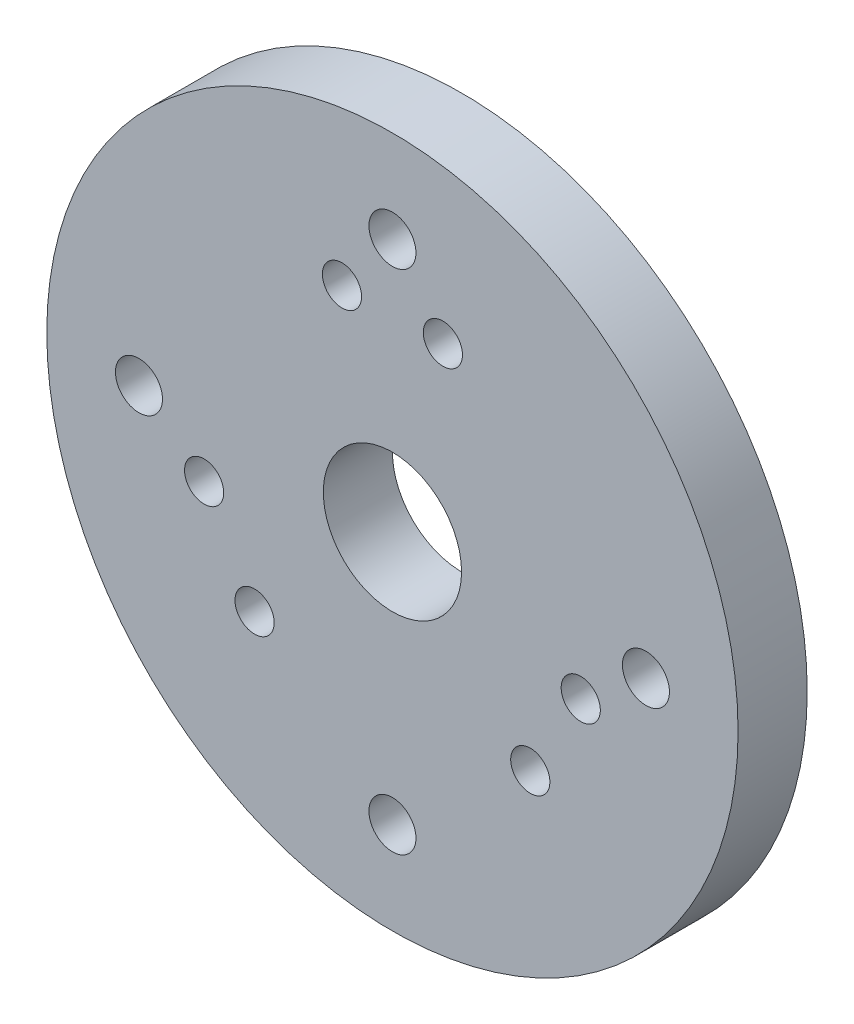
from build123d import *

# Parameters (mm, degrees)
ESQUISSE1_R        = 75
ESQUISSE1_R_2      = 15
ESQUISSE1_R_3      = 5.1
ESQUISSE1_R_4      = 4.25
BOSS_EXTRU_1_DEPTH = 7.5


with BuildPart() as part:
    # Esquisse1 → Boss.-Extru.1 (new body, symmetric)
    with BuildSketch(Plane.XY):
        Circle(ESQUISSE1_R)
        Circle(ESQUISSE1_R_2, mode=Mode.SUBTRACT)
        with Locations((0, 55)):
            Circle(ESQUISSE1_R_3, mode=Mode.SUBTRACT)
        with Locations((-55, 0)):
            Circle(ESQUISSE1_R_3, mode=Mode.SUBTRACT)
        with Locations((0, -55)):
            Circle(ESQUISSE1_R_3, mode=Mode.SUBTRACT)
        with Locations((55, 0)):
            Circle(ESQUISSE1_R_3, mode=Mode.SUBTRACT)
        with Locations((10.948045608, 40.858662452)):
            Circle(ESQUISSE1_R_4, mode=Mode.SUBTRACT)
        with Locations(Location((-10.948045608, 40.858662452, 0), (0, 0, 180))):  # turned: the seam where the file's is
            Circle(ESQUISSE1_R_4, mode=Mode.SUBTRACT)
        with Locations((29.910616844, -29.910616844)):
            Circle(ESQUISSE1_R_4, mode=Mode.SUBTRACT)
        with Locations(Location((40.858662452, -10.948045608, 0), (0, 0, 180))):  # turned: the seam where the file's is
            Circle(ESQUISSE1_R_4, mode=Mode.SUBTRACT)
        with Locations((-40.858662452, -10.948045608)):
            Circle(ESQUISSE1_R_4, mode=Mode.SUBTRACT)
        with Locations(Location((-29.910616844, -29.910616844, 0), (0, 0, 180))):  # turned: the seam where the file's is
            Circle(ESQUISSE1_R_4, mode=Mode.SUBTRACT)
    extrude(amount=BOSS_EXTRU_1_DEPTH, both=True)


solid = part.part
